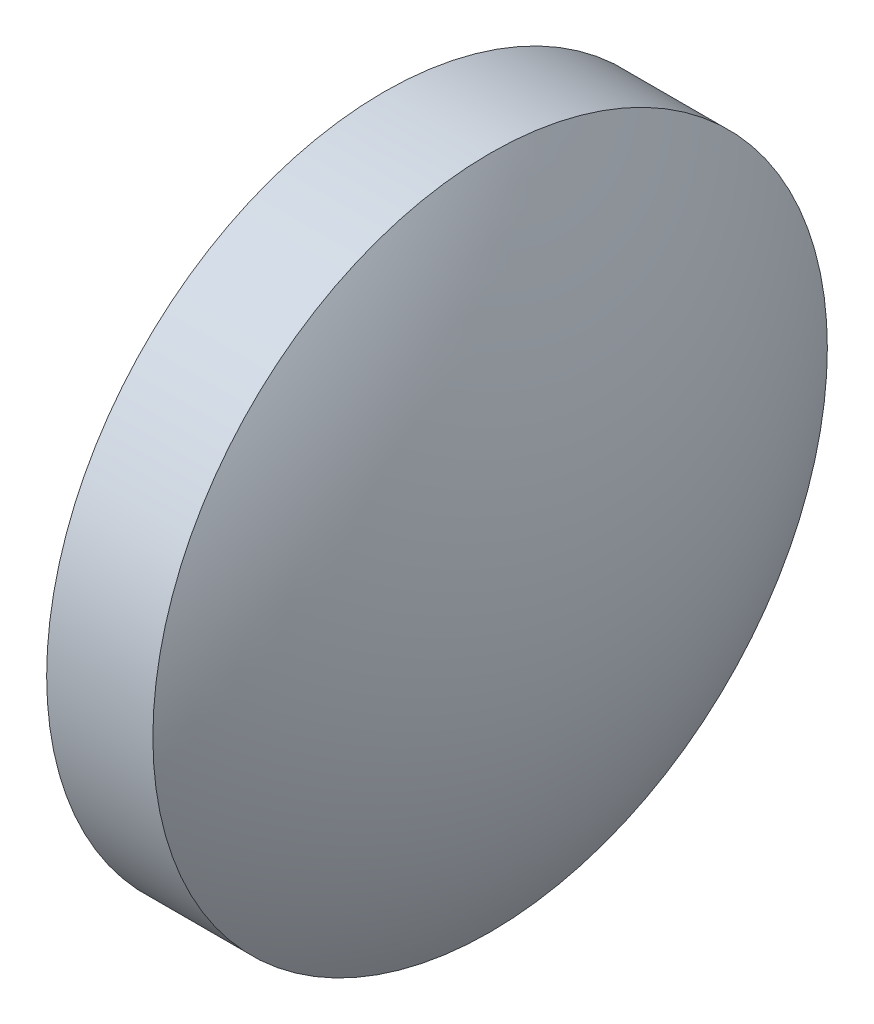
from build123d import *

# Parameters (mm, degrees)
SKETCH_1_ONE_SIDE_W = 2.000068571
SKETCH_1_ONE_SIDE_H = 6.35


with BuildPart() as part:
    # 草图1 one side → 旋转1 (revolve)
    with BuildSketch(Plane.XY, mode=Mode.PRIVATE) as revolve_1_sk:
        with Locations((43.229096888, 27.483056512)):
            Rectangle(SKETCH_1_ONE_SIDE_W, SKETCH_1_ONE_SIDE_H)
        with BuildLine():
            Line((40.429109744, 24.308056512), (42.229062602, 24.308056512))
            Line((42.229062602, 24.308056512), (42.229062602, 30.658056512))
            ThreePointArc((42.229062602, 30.658056512), (40.887791006, 27.608144779), (40.429109744, 24.308056512))
        make_face()
        with BuildLine():
            Line((44.229131173, 24.308056512), (46.02908403, 24.308056512))
            ThreePointArc((46.02908403, 24.308056512), (45.570402769, 27.608144779), (44.229131173, 30.658056512))
            Line((44.229131173, 30.658056512), (44.229131173, 24.308056512))
        make_face()
    revolve(revolve_1_sk.sketch.rotate(Axis((39.652700675, 24.308056512, 0), (1, 0, 0)), 90), axis=Axis((39.652700675, 24.308056512, 0), (1, 0, 0)))  # turned: the seam where the file's is


solid = part.part
